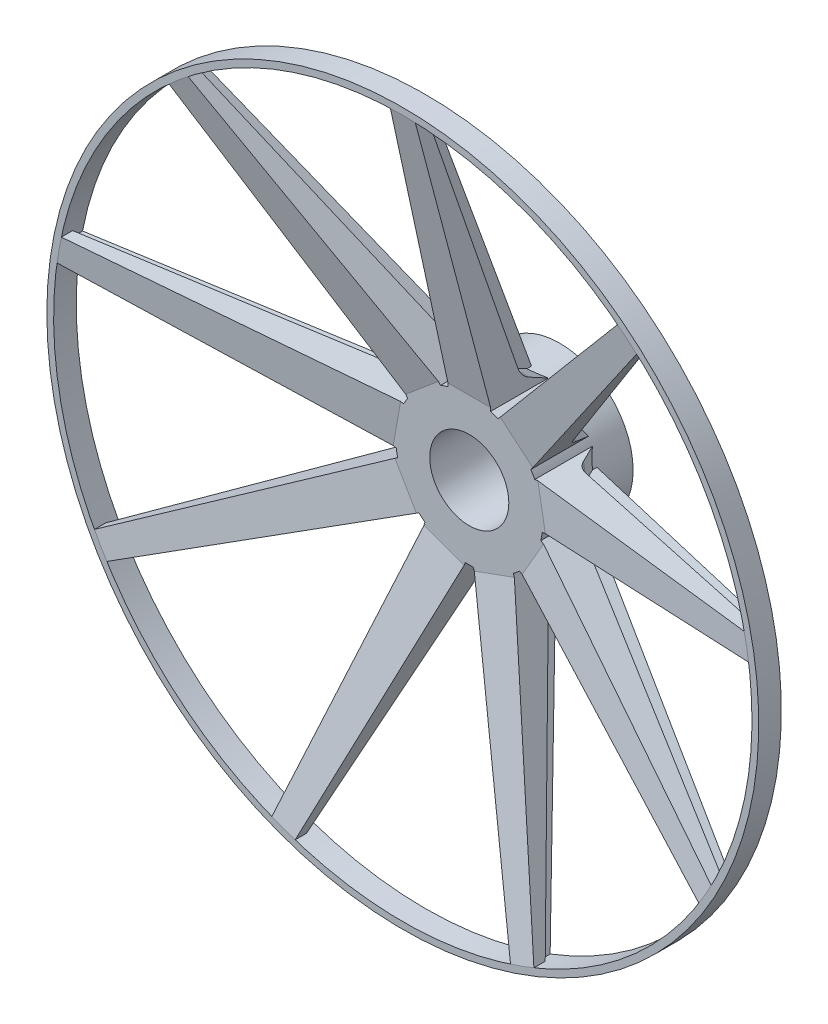
from build123d import *

# Parameters (mm, degrees)
SKETCH1_R                = 32.5
SKETCH1_R_2              = 17.5
BOSS_EXTRUDE1_DEPTH      = 40
BOSS_EXTRUDE2_DEPTH      = 9.5
BOSS_EXTRUDE2_DEPTH_BACK = 9.5
SKETCH6_W                = 19
SKETCH6_H                = 1.948836008
BOSS_EXTRUDE3_DEPTH      = 25
BOSS_EXTRUDE4_DEPTH      = 19
CUT_EXTRUDE3_DEPTH       = 7
CUT_EXTRUDE6_DEPTH       = 173.462942043
CIRPATTERN11_COUNT       = 9
SKETCH21_R               = 157.5
SKETCH21_R_2             = 154.5
BOSS_EXTRUDE5_DEPTH      = 10


with BuildPart() as part:
    # Sketch1 → Boss-Extrude1 (new body)
    with BuildSketch(Plane.XY):
        Circle(SKETCH1_R)
        Circle(SKETCH1_R_2, mode=Mode.SUBTRACT)
    extrude(amount=BOSS_EXTRUDE1_DEPTH)



with BuildPart() as body_2:
    # Sketch4 → Boss-Extrude2 (new, two sides: drawn at the far end of the back side and taken through both)
    with BuildSketch(Plane(origin=(0, 0, 0), x_dir=(0, 0, -1), z_dir=(1, 0, 0)).offset(-BOSS_EXTRUDE2_DEPTH_BACK)):
        Polygon((-40, 32.5), (-15, 32.5), (-59.40436858, 154.5), (-69.40436858, 154.5), align=None)
    extrude(amount=BOSS_EXTRUDE2_DEPTH + BOSS_EXTRUDE2_DEPTH_BACK)


with BuildPart() as part_1:
    add(part.part)

    add(body_2.part)  # Boss-Extrude3 merges body 2
    # Sketch6 → Boss-Extrude3 (add)
    with BuildSketch(Plane.XY.offset(40)):
        with Locations((0, 31.525581996)):
            Rectangle(SKETCH6_W, SKETCH6_H)
    extrude(amount=-BOSS_EXTRUDE3_DEPTH)

    # Sketch7 → Boss-Extrude4 (add)
    with BuildSketch(Plane(origin=(9.5, 0, 0), x_dir=(0, 0, -1), z_dir=(1, 0, 0))):
        Polygon((-14.483359006, 31.080540536), (-15, 32.5), (-15, 31.080540536), align=None)
    extrude(amount=-BOSS_EXTRUDE4_DEPTH)

    # Sketch10 → Cut-Extrude3 (cut)
    with BuildSketch(Plane.ZY.offset(9.5)):
        with BuildLine():
            Line((64.40436858, 154.5), (27.68555889, 41.310853262))
            ThreePointArc((27.68555889, 41.310853262), (25.843897734, 37.980517522), (22.891351203, 35.57940925))
            Line((22.891351203, 35.57940925), (14.483359006, 31.080540536))
            Line((14.483359006, 31.080540536), (59.40436858, 154.5))
            Line((59.40436858, 154.5), (64.40436858, 154.5))
        make_face()
    cut_extrude3 = extrude(amount=-CUT_EXTRUDE3_DEPTH, mode=Mode.SUBTRACT)

    # Mirror1: Cut-Extrude3 across plane
    add(cut_extrude3.mirror(Plane(origin=(0, 0, 0), x_dir=(0, 0, 1), z_dir=(1, 0, 0))), mode=Mode.SUBTRACT)

    # Sketch20 → Cut-Extrude6 (cut, through all)
    with BuildSketch(Plane(origin=(0, 0, 0), x_dir=(-1, 0, 0), z_dir=(0, 0, -1))):
        Polygon((5.5, 154.5), (9.5, 29.704419373), (9.5, 154.5), align=None)
        Polygon((-5.5, 154.5), (-9.5, 31.080540536), (-9.5, 154.5), align=None)
    extrude(amount=-CUT_EXTRUDE6_DEPTH, mode=Mode.SUBTRACT)


with BuildPart() as cirpattern11_1:
    # CirPattern11: pattern copy
    add(part_1.part.rotate(Axis((0, 0, 0), (0, 0, 1)), 1 * 360 / CIRPATTERN11_COUNT))


with BuildPart() as cirpattern11_2:
    # CirPattern11: pattern copy
    add(part_1.part.rotate(Axis((0, 0, 0), (0, 0, 1)), 2 * 360 / CIRPATTERN11_COUNT))


with BuildPart() as cirpattern11_3:
    # CirPattern11: pattern copy
    add(part_1.part.rotate(Axis((0, 0, 0), (0, 0, 1)), 3 * 360 / CIRPATTERN11_COUNT))


with BuildPart() as cirpattern11_4:
    # CirPattern11: pattern copy
    add(part_1.part.rotate(Axis((0, 0, 0), (0, 0, 1)), 4 * 360 / CIRPATTERN11_COUNT))


with BuildPart() as cirpattern11_5:
    # CirPattern11: pattern copy
    add(part_1.part.rotate(Axis((0, 0, 0), (0, 0, 1)), 5 * 360 / CIRPATTERN11_COUNT))


with BuildPart() as cirpattern11_6:
    # CirPattern11: pattern copy
    add(part_1.part.rotate(Axis((0, 0, 0), (0, 0, 1)), 6 * 360 / CIRPATTERN11_COUNT))


with BuildPart() as cirpattern11_7:
    # CirPattern11: pattern copy
    add(part_1.part.rotate(Axis((0, 0, 0), (0, 0, 1)), 7 * 360 / CIRPATTERN11_COUNT))


with BuildPart() as cirpattern11_8:
    # CirPattern11: pattern copy
    add(part_1.part.rotate(Axis((0, 0, 0), (0, 0, 1)), 8 * 360 / CIRPATTERN11_COUNT))


with BuildPart() as part_2:
    add(part_1.part)

    add(cirpattern11_1.part)  # Boss-Extrude5 merges CirPattern11_1

    add(cirpattern11_2.part)  # Boss-Extrude5 merges CirPattern11_2

    add(cirpattern11_3.part)  # Boss-Extrude5 merges CirPattern11_3

    add(cirpattern11_4.part)  # Boss-Extrude5 merges CirPattern11_4

    add(cirpattern11_5.part)  # Boss-Extrude5 merges CirPattern11_5

    add(cirpattern11_6.part)  # Boss-Extrude5 merges CirPattern11_6

    add(cirpattern11_7.part)  # Boss-Extrude5 merges CirPattern11_7

    add(cirpattern11_8.part)  # Boss-Extrude5 merges CirPattern11_8
    # Sketch21 → Boss-Extrude5 (add)
    with BuildSketch(Plane(origin=(0, 0, 69.40436858), x_dir=(-1, 0, 0), z_dir=(0, 0, -1))):
        Circle(SKETCH21_R)
        Circle(SKETCH21_R_2, mode=Mode.SUBTRACT)
    extrude(amount=BOSS_EXTRUDE5_DEPTH)


solid = part_2.part
